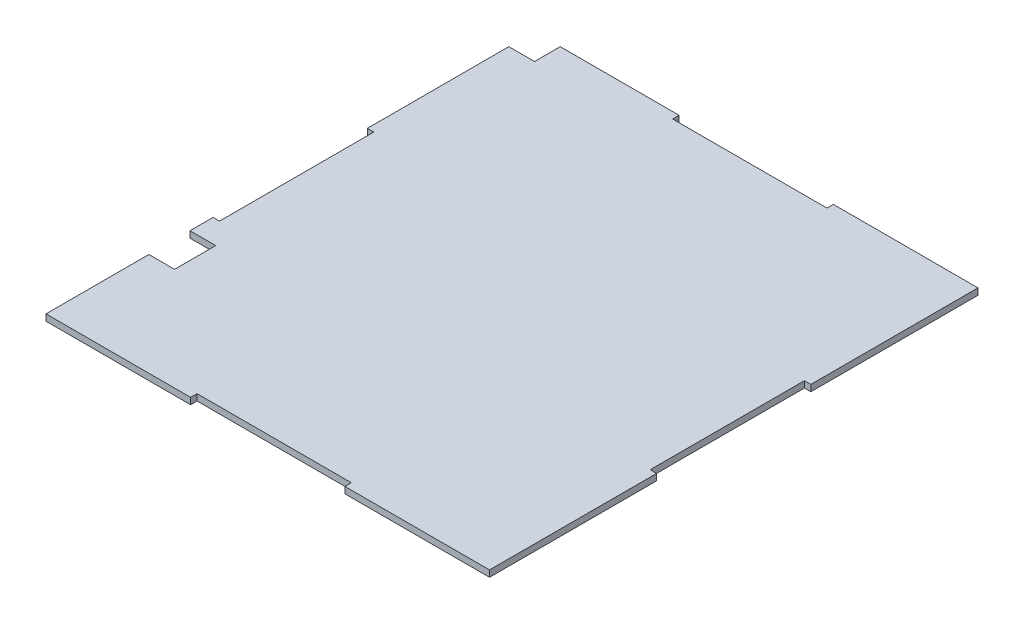
from build123d import *

# Parameters (mm, degrees)
SKETCH2_W           = 219.075
SKETCH2_H           = 241.3
BOSS_EXTRUDE1_DEPTH = 3.175
SKETCH3_W           = 3.175
SKETCH3_H           = 76.2
SKETCH3_W_2         = 76.2
SKETCH3_H_2         = 3.175
CUT_EXTRUDE1_DEPTH  = 4.175
SKETCH4_W           = 12.7
SKETCH4_H           = 20.32
SKETCH4_H_2         = 12.7
CUT_EXTRUDE2_DEPTH  = 4.175


with BuildPart() as part:
    # Sketch2 → Boss-Extrude1 (new body)
    with BuildSketch(Plane(origin=(0, 0, 0), x_dir=(1, 0, 0), z_dir=(0, 1, 0))):
        with Locations((109.5375, 120.65)):
            Rectangle(SKETCH2_W, SKETCH2_H)
    extrude(amount=BOSS_EXTRUDE1_DEPTH)

    # Sketch3 → Cut-Extrude1 (cut, through all)
    with BuildSketch(Plane(origin=(0, 3.175, 0), x_dir=(1, 0, 0), z_dir=(0, 1, 0))):
        with Locations((1.5875, 120.65)):
            Rectangle(SKETCH3_W, SKETCH3_H)
        with Locations((217.4875, 120.65)):
            Rectangle(SKETCH3_W, SKETCH3_H)
        with Locations((109.5375, 239.7125)):
            Rectangle(SKETCH3_W_2, SKETCH3_H_2)
        with Locations((109.5375, 1.5875)):
            Rectangle(SKETCH3_W_2, SKETCH3_H_2)
    extrude(amount=-CUT_EXTRUDE1_DEPTH, mode=Mode.SUBTRACT)

    # Sketch4 → Cut-Extrude2 (cut, through all)
    with BuildSketch(Plane(origin=(0, 3.175, 0), x_dir=(1, 0, 0), z_dir=(0, 1, 0))):
        with Locations((6.35, 60.96)):
            Rectangle(SKETCH4_W, SKETCH4_H)
        with Locations((6.35, 234.95)):
            Rectangle(SKETCH4_W, SKETCH4_H_2)
    extrude(amount=-CUT_EXTRUDE2_DEPTH, mode=Mode.SUBTRACT)


solid = part.part
